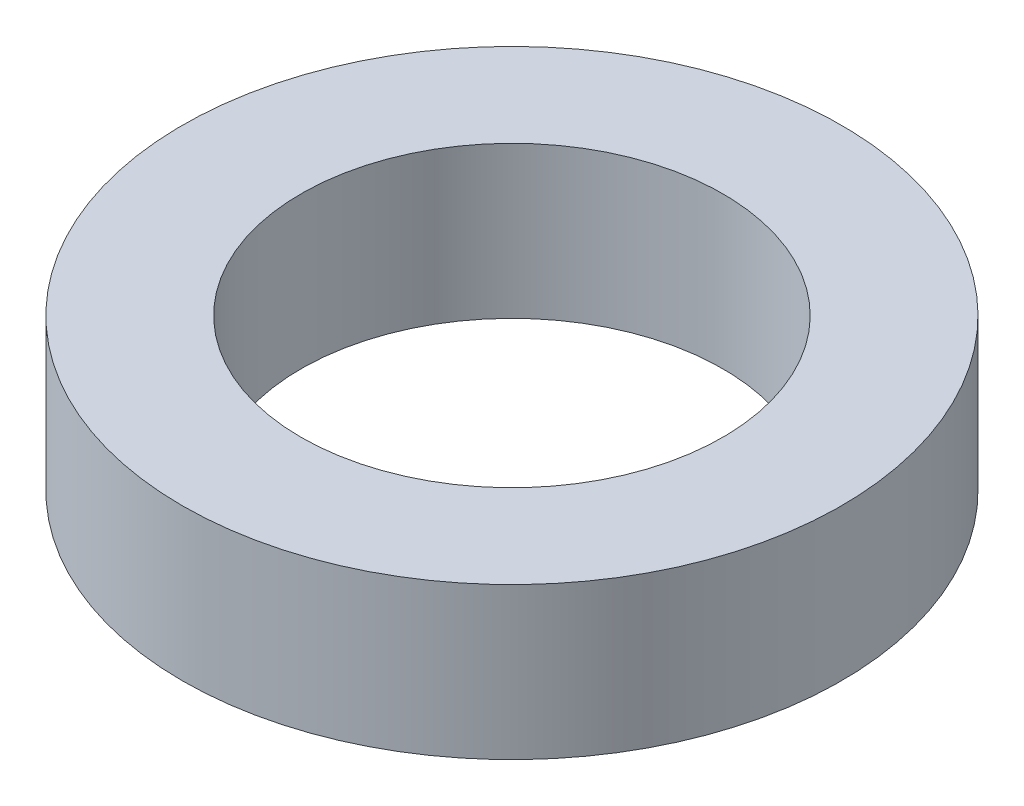
from build123d import *

# Parameters (mm, degrees)
SKETCH1_R           = 5
SKETCH1_R_2         = 3.2
BOSS_EXTRUDE1_DEPTH = 2.3


with BuildPart() as part:
    # Sketch1 → Boss-Extrude1 (new body)
    with BuildSketch(Plane(origin=(0, 0, 0), x_dir=(1, 0, 0), z_dir=(0, 1, 0))):
        Circle(SKETCH1_R)
        Circle(SKETCH1_R_2, mode=Mode.SUBTRACT)
    extrude(amount=BOSS_EXTRUDE1_DEPTH)


solid = part.part
